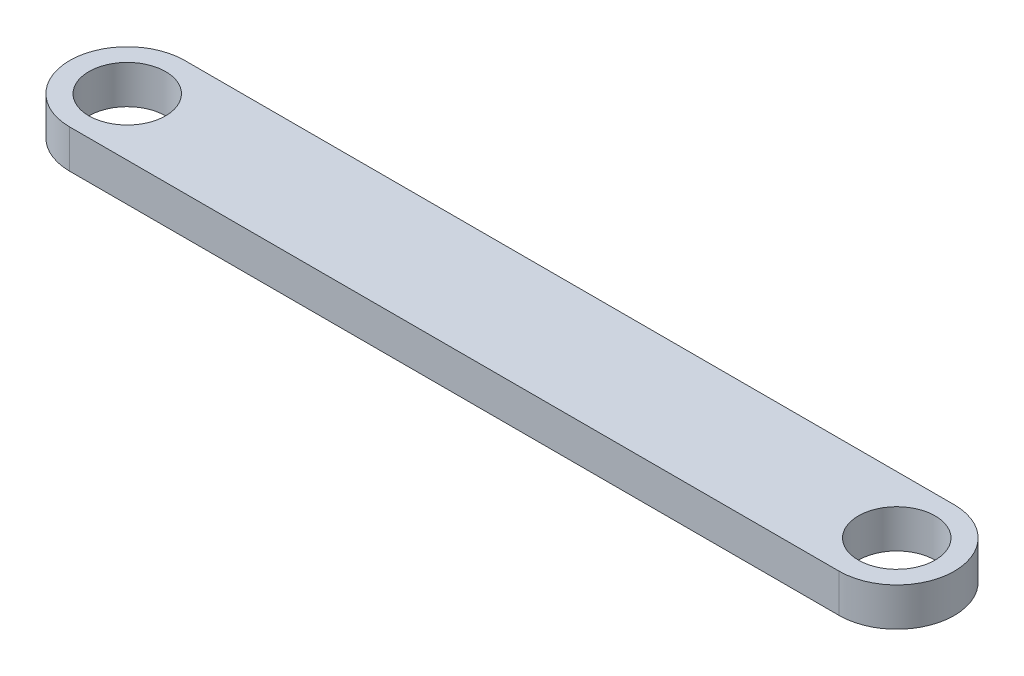
from build123d import *

# Parameters (mm, degrees)
SKETCH_1_R      = 5
EXTRUDE_1_DEPTH = 5


with BuildPart() as part:
    # 草图1 → 凸台-拉伸1 (new body)
    with BuildSketch(Plane(origin=(0, 0, 0), x_dir=(1, 0, 0), z_dir=(0, 1, 0))):
        with BuildLine():
            Line((0, 7.5), (100.280855601, 7.5))
            ThreePointArc((100.280855601, 7.5), (107.780855601, 0), (100.280855601, -7.5))
            Line((100.280855601, -7.5), (0, -7.5))
            ThreePointArc((0, -7.5), (-7.5, 0), (0, 7.5))
        make_face()
        Circle(SKETCH_1_R, mode=Mode.SUBTRACT)
        with Locations((100.280855601, 0)):
            Circle(SKETCH_1_R, mode=Mode.SUBTRACT)
    extrude(amount=EXTRUDE_1_DEPTH)


solid = part.part
